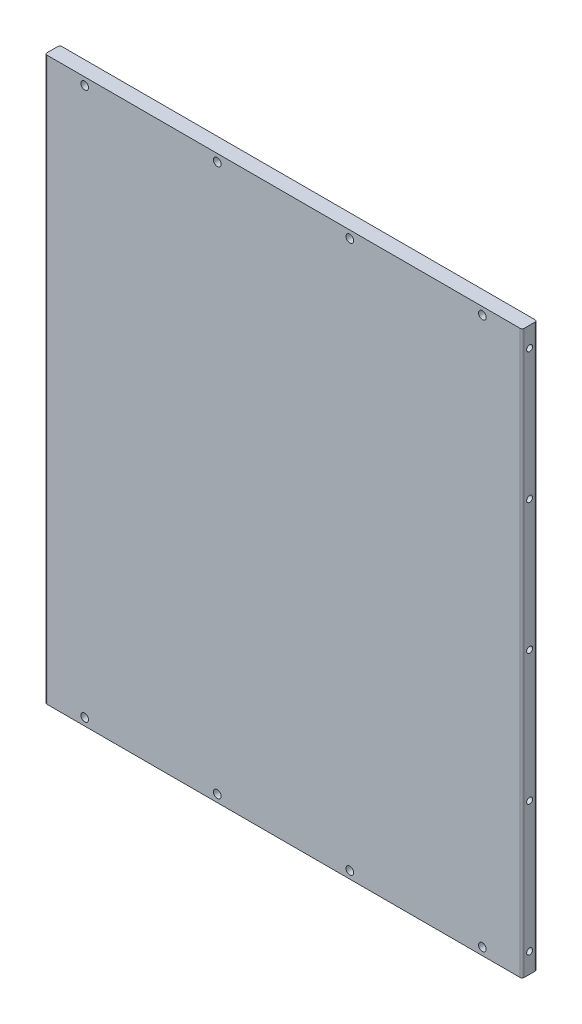
from build123d import *

# Parameters (mm, degrees)
SKETCH1_W                       = 304.8
SKETCH1_H                       = 359.05
BOSS_EXTRUDE1_DEPTH             = 9.525
F_10_24_TAPPED_HOLE1_AT_2_COUNT = 2
F_10_24_TAPPED_HOLE1_AT_2_PITCH = 83.4125
F_10_24_TAPPED_HOLE1_AT_3_COUNT = 2
F_10_24_TAPPED_HOLE1_AT_3_PITCH = 166.825
F_10_24_TAPPED_HOLE1_AT_4_COUNT = 2
F_10_24_TAPPED_HOLE1_AT_4_PITCH = 250.2375
F_10_24_TAPPED_HOLE1_AT_5_COUNT = 2
F_10_24_TAPPED_HOLE1_AT_5_PITCH = 333.65
F_10_0_1935_DIAMETER_HOLE2_D    = 4.9149
FILLET2_R                       = 1.27


with BuildPart() as part:
    # Sketch1 → Boss-Extrude1 (new body)
    with BuildSketch(Plane.XY):
        with Locations((-102.750000669, -245)):
            Rectangle(SKETCH1_W, SKETCH1_H)
    extrude(amount=BOSS_EXTRUDE1_DEPTH)

    # Sketch3 → #10-24 Tapped Hole1 (revolve, cut)
    with BuildSketch(Plane(origin=(49.649999331, -411.825, 4.7625), x_dir=(0, 0, -1), z_dir=(0, 1, 0))):
        Polygon((0, 0), (0, 20.190824014), (1.89865, 19.05), (1.89865, 0), align=None)
    f_10_24_tapped_hole1 = revolve(axis=Axis((55.999999331, -411.825, 4.7625), (-1, 0, 0)), mode=Mode.SUBTRACT)

    # #10-24 Tapped Hole1 at 2: #10-24 Tapped Hole1 ×2
    with Locations(*[(0, i * F_10_24_TAPPED_HOLE1_AT_2_PITCH, 0) for i in range(1, F_10_24_TAPPED_HOLE1_AT_2_COUNT)]):
        add(f_10_24_tapped_hole1, mode=Mode.SUBTRACT)

    # #10-24 Tapped Hole1 at 3: #10-24 Tapped Hole1 ×2
    with Locations(*[(0, i * F_10_24_TAPPED_HOLE1_AT_3_PITCH, 0) for i in range(1, F_10_24_TAPPED_HOLE1_AT_3_COUNT)]):
        add(f_10_24_tapped_hole1, mode=Mode.SUBTRACT)

    # #10-24 Tapped Hole1 at 4: #10-24 Tapped Hole1 ×2
    with Locations(*[(0, i * F_10_24_TAPPED_HOLE1_AT_4_PITCH, 0) for i in range(1, F_10_24_TAPPED_HOLE1_AT_4_COUNT)]):
        add(f_10_24_tapped_hole1, mode=Mode.SUBTRACT)

    # #10-24 Tapped Hole1 at 5: #10-24 Tapped Hole1 ×2
    with Locations(*[(0, i * F_10_24_TAPPED_HOLE1_AT_5_PITCH, 0) for i in range(1, F_10_24_TAPPED_HOLE1_AT_5_COUNT)]):
        add(f_10_24_tapped_hole1, mode=Mode.SUBTRACT)

    # #10 (0.1935) Diameter Hole2 (through all)
    with Locations(Plane.XY.offset(9.525)):
        with Locations((-229.750000669, -70.2375), (-145.083334002, -70.2375), (-60.416667336, -70.2375), (24.249999331, -70.2375), (-229.750000669, -419.7625), (-145.083334002, -419.7625), (-60.416667336, -419.7625), (24.249999331, -419.7625)):
            Hole(F_10_0_1935_DIAMETER_HOLE2_D / 2)

    # Mirror1: #10-24 Tapped Hole1 across plane
    add(f_10_24_tapped_hole1.mirror(Plane(origin=(-102.750000669, 0, 0), x_dir=(0, 0, 1), z_dir=(1, 0, 0))), mode=Mode.SUBTRACT)

    # Mirror1 copy 1 sketch → Mirror1 copy 1 (revolve, cut)
    with BuildSketch(Plane(origin=(-255.150000669, -328.4125, 4.7625), x_dir=(0, 0, -1), z_dir=(0, 1, 0))):
        Polygon((0, 0), (0, -20.190824014), (1.89865, -19.05), (1.89865, 0), align=None)
    revolve(axis=Axis((-261.500000669, -328.4125, 4.7625), (-1, 0, 0)), mode=Mode.SUBTRACT)

    # Mirror1 copy 2 sketch → Mirror1 copy 2 (revolve, cut)
    with BuildSketch(Plane(origin=(-255.150000669, -245, 4.7625), x_dir=(0, 0, -1), z_dir=(0, 1, 0))):
        Polygon((0, 0), (0, -20.190824014), (1.89865, -19.05), (1.89865, 0), align=None)
    revolve(axis=Axis((-261.500000669, -245, 4.7625), (-1, 0, 0)), mode=Mode.SUBTRACT)

    # Mirror1 copy 3 sketch → Mirror1 copy 3 (revolve, cut)
    with BuildSketch(Plane(origin=(-255.150000669, -161.5875, 4.7625), x_dir=(0, 0, -1), z_dir=(0, 1, 0))):
        Polygon((0, 0), (0, -20.190824014), (1.89865, -19.05), (1.89865, 0), align=None)
    revolve(axis=Axis((-261.500000669, -161.5875, 4.7625), (-1, 0, 0)), mode=Mode.SUBTRACT)

    # Mirror1 copy 4 sketch → Mirror1 copy 4 (revolve, cut)
    with BuildSketch(Plane(origin=(-255.150000669, -78.175, 4.7625), x_dir=(0, 0, -1), z_dir=(0, 1, 0))):
        Polygon((0, 0), (0, -20.190824014), (1.89865, -19.05), (1.89865, 0), align=None)
    revolve(axis=Axis((-261.500000669, -78.175, 4.7625), (-1, 0, 0)), mode=Mode.SUBTRACT)

    # Fillet2
    fillet2_edges = [part.edges().sort_by_distance(p)[0] for p in [
        (-255.150000669, -245, 9.525),
        (49.649999331, -245, 9.525),
        (-255.150000669, -245, 0),
        (49.649999331, -245, 0),
    ]]
    fillet(fillet2_edges, radius=FILLET2_R)


solid = part.part
